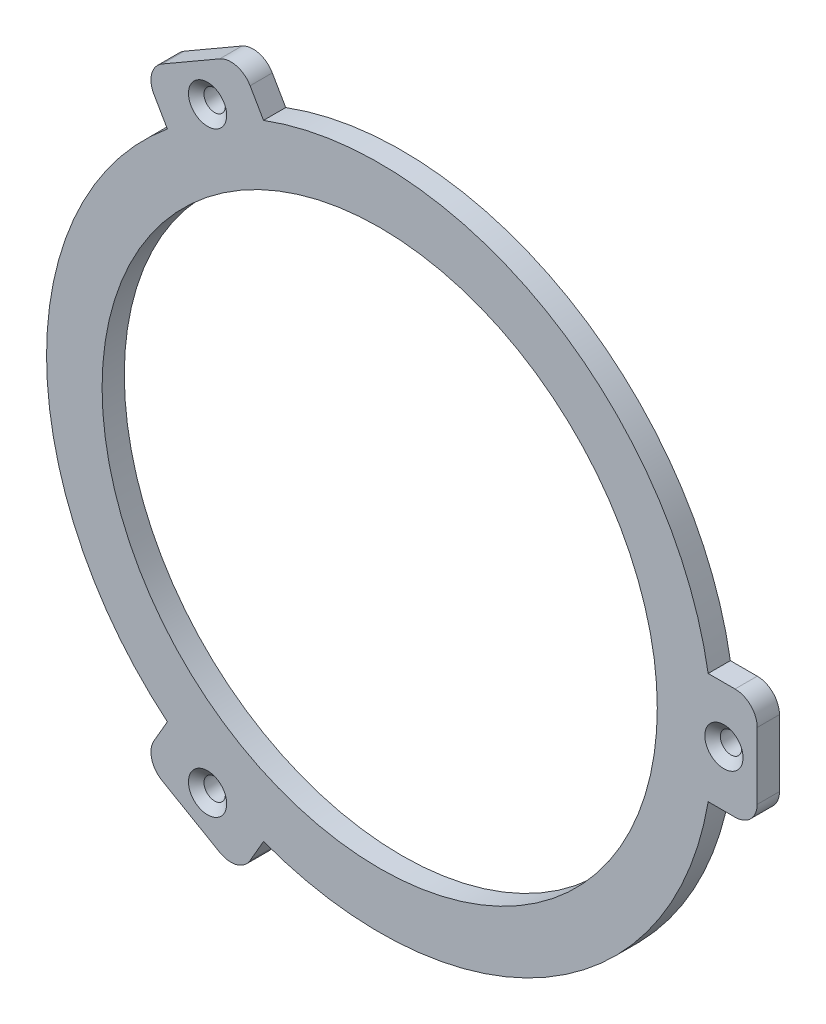
from build123d import *

# Parameters (mm, degrees)
SKETCH1_R                                         = 38.1
SKETCH1_R_2                                       = 31.75
BOSS_EXTRUDE1_DEPTH                               = 2.54
SKETCH2_W                                         = 10.16
SKETCH2_H                                         = 12.7
BOSS_EXTRUDE2_DEPTH                               = 2.54
FILLET1_R                                         = 2.54
SKETCH3_R                                         = 0.635
CUT_EXTRUDE1_DEPTH                                = 3.54
CSK_FOR_2_FLAT_HEAD_MACHINE_SCREW_100_D           = 2.4384
CSK_FOR_2_FLAT_HEAD_MACHINE_SCREW_100_CSINK_D     = 4.3688
CSK_FOR_2_FLAT_HEAD_MACHINE_SCREW_100_CSINK_ANGLE = 100
CIRPATTERN1_COUNT                                 = 3
FILLET1_OF_CIRPATTERN1_R                          = 2.54
SKETCH6_R                                         = 36.9697
SKETCH6_R_2                                       = 34.544
CUT_EXTRUDE3_DEPTH                                = 1.27


with BuildPart() as part:
    # Sketch1 → Boss-Extrude1 (new body)
    with BuildSketch(Plane.XY):
        Circle(SKETCH1_R)
        Circle(SKETCH1_R_2, mode=Mode.SUBTRACT)
    extrude(amount=BOSS_EXTRUDE1_DEPTH)

    # Sketch2 → Boss-Extrude2 (add)
    with BuildSketch(Plane.XY):
        with Locations((38.1, 0)):
            Rectangle(SKETCH2_W, SKETCH2_H)
    boss_extrude2 = extrude(amount=BOSS_EXTRUDE2_DEPTH)

    # Fillet1
    fillet1_edges = [part.edges().sort_by_distance(p)[0] for p in [
        (43.18, 6.35, 1.27),
        (43.18, -6.35, 1.27),
    ]]
    fillet(fillet1_edges, radius=FILLET1_R)

    # Sketch3 → Cut-Extrude1 (cut, through all)
    with BuildSketch(Plane.XY.offset(2.54)):
        with Locations((39.37, 0)):
            Circle(SKETCH3_R)
    cut_extrude1 = extrude(amount=-CUT_EXTRUDE1_DEPTH, mode=Mode.SUBTRACT)

    # CSK for #2 Flat Head Machine Screw (100)1 (through all)
    with Locations(Plane.XY.offset(2.54)):
        with Locations((39.37, 0)):
            csk_for_2_flat_head_machine_screw_100 = CounterSinkHole(CSK_FOR_2_FLAT_HEAD_MACHINE_SCREW_100_D / 2, CSK_FOR_2_FLAT_HEAD_MACHINE_SCREW_100_CSINK_D / 2, counter_sink_angle=CSK_FOR_2_FLAT_HEAD_MACHINE_SCREW_100_CSINK_ANGLE)

    # CirPattern1: Boss-Extrude2, Cut-Extrude1, CSK for #2 Flat Head Machine Screw (100)1 ×3 about axis
    cirpattern1_axis = Axis((0, 0, 0), (0, 0, 1))
    for i in range(1, CIRPATTERN1_COUNT):
        add(boss_extrude2.rotate(cirpattern1_axis, i * 360 / CIRPATTERN1_COUNT))
        add(cut_extrude1.rotate(cirpattern1_axis, i * 360 / CIRPATTERN1_COUNT), mode=Mode.SUBTRACT)
        add(csk_for_2_flat_head_machine_screw_100.rotate(cirpattern1_axis, i * 360 / CIRPATTERN1_COUNT), mode=Mode.SUBTRACT)

    # Fillet1 of CirPattern1
    fillet1_of_cirpattern1_edges = [part.edges().sort_by_distance(p)[0] for p in [
        (-27.089261314, 34.219976935, 1.27),
        (-16.090738686, 40.569976935, 1.27),
        (-16.090738686, -40.569976935, 1.27),
        (-27.089261314, -34.219976935, 1.27),
    ]]
    fillet(fillet1_of_cirpattern1_edges, radius=FILLET1_OF_CIRPATTERN1_R)

    # Sketch6 → Cut-Extrude3 (cut)
    with BuildSketch(Plane(origin=(0, 0, 0), x_dir=(-1, 0, 0), z_dir=(0, 0, -1))):
        Circle(SKETCH6_R)
        Circle(SKETCH6_R_2, mode=Mode.SUBTRACT)
    extrude(amount=-CUT_EXTRUDE3_DEPTH, mode=Mode.SUBTRACT)


solid = part.part
